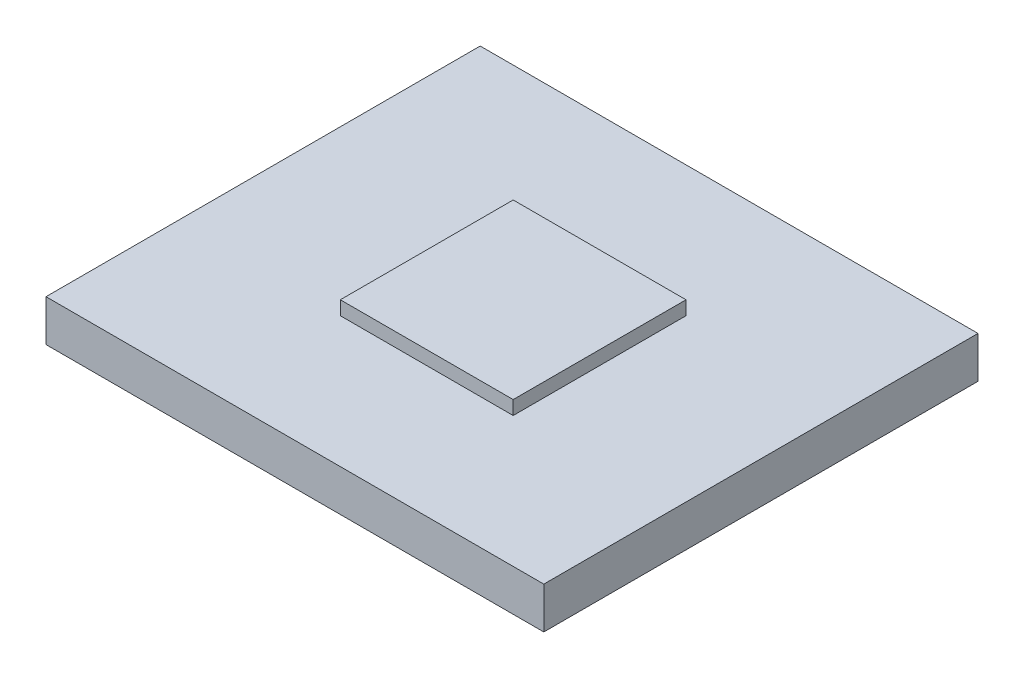
from build123d import *

# Parameters (mm, degrees)
CROQUIS1_W              = 18
CROQUIS1_H              = 15.7
SALIENTE_EXTRUIR1_DEPTH = 1.5
CROQUIS2_W              = 6.25
CROQUIS2_H              = 6.25
SALIENTE_EXTRUIR2_DEPTH = 0.5


with BuildPart() as part:
    # Croquis1 → Saliente-Extruir1 (new body)
    with BuildSketch(Plane.XZ):
        with Locations((9, 0)):
            Rectangle(CROQUIS1_W, CROQUIS1_H)
    extrude(amount=SALIENTE_EXTRUIR1_DEPTH)

    # Croquis2 → Saliente-Extruir2 (add)
    with BuildSketch(Plane(origin=(0, 0, 0), x_dir=(1, 0, 0), z_dir=(0, 1, 0))):
        with Locations((9.04271605, 0)):
            Rectangle(CROQUIS2_W, CROQUIS2_H)
    extrude(amount=SALIENTE_EXTRUIR2_DEPTH)


solid = part.part
